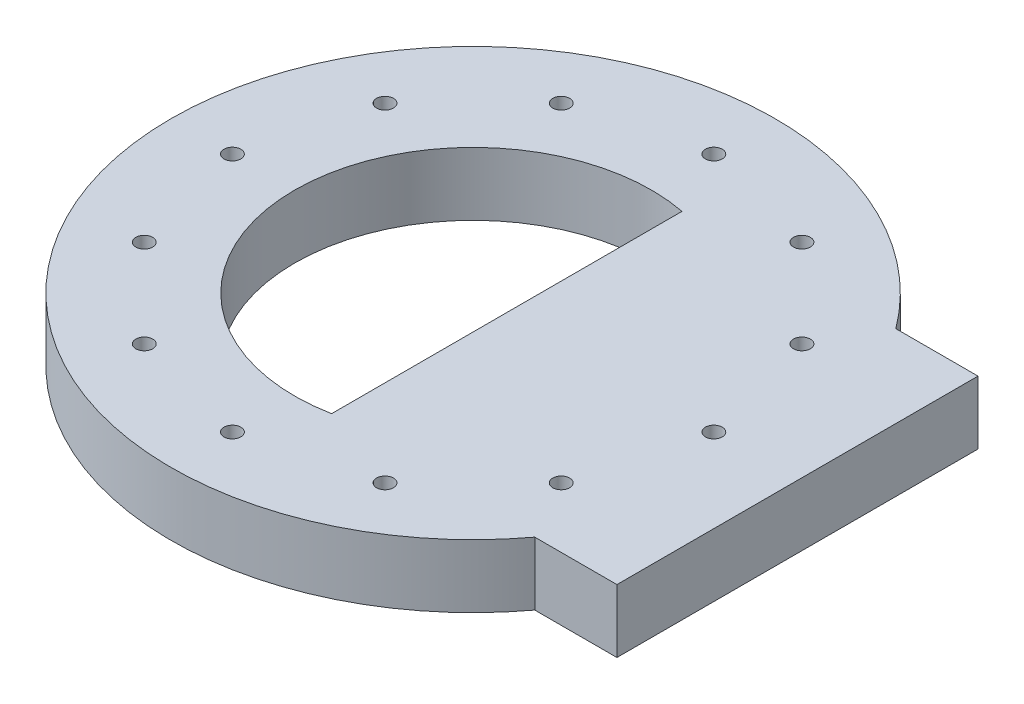
from build123d import *

# Parameters (mm, degrees)
SKETCH1_R           = 127.508
SKETCH1_R_2         = 75.311
SKETCH1_R_3         = 3.5687
BOSS_EXTRUDE1_DEPTH = 26.67
BOSS_EXTRUDE2_DEPTH = 26.67


with BuildPart() as part:
    # Sketch1 → Boss-Extrude1 (new body)
    with BuildSketch(Plane(origin=(0, 0, 0), x_dir=(1, 0, 0), z_dir=(0, 1, 0))):
        Circle(SKETCH1_R)
        Circle(SKETCH1_R_2, mode=Mode.SUBTRACT)
        with Locations((0, 101.6)):
            Circle(SKETCH1_R_3, mode=Mode.SUBTRACT)
        with Locations((50.8, 87.988181024)):
            Circle(SKETCH1_R_3, mode=Mode.SUBTRACT)
        with Locations((87.988181025, 50.8)):
            Circle(SKETCH1_R_3, mode=Mode.SUBTRACT)
        with Locations((101.6, 0)):
            Circle(SKETCH1_R_3, mode=Mode.SUBTRACT)
        with Locations((87.988181025, -50.8)):
            Circle(SKETCH1_R_3, mode=Mode.SUBTRACT)
        with Locations((50.8, -87.988181024)):
            Circle(SKETCH1_R_3, mode=Mode.SUBTRACT)
        with Locations((0, -101.6)):
            Circle(SKETCH1_R_3, mode=Mode.SUBTRACT)
        with Locations((-50.8, -87.988181025)):
            Circle(SKETCH1_R_3, mode=Mode.SUBTRACT)
        with Locations((-87.988181024, -50.8)):
            Circle(SKETCH1_R_3, mode=Mode.SUBTRACT)
        with Locations((-101.6, 0)):
            Circle(SKETCH1_R_3, mode=Mode.SUBTRACT)
        with Locations((-87.988181024, 50.8)):
            Circle(SKETCH1_R_3, mode=Mode.SUBTRACT)
        with Locations((-50.8, 87.988181024)):
            Circle(SKETCH1_R_3, mode=Mode.SUBTRACT)
    extrude(amount=BOSS_EXTRUDE1_DEPTH)

    # Sketch2 → Boss-Extrude2 (add, through all)
    with BuildSketch(Plane(origin=(0, 26.67, 0), x_dir=(1, 0, 0), z_dir=(0, 1, 0))):
        with BuildLine():
            Line((14.224, 73.955557905), (14.224, -73.955557905))
            ThreePointArc((14.224, -73.955557905), (75.311, 0), (14.224, 73.955557905))
        make_face()
        with BuildLine():
            Line((136.906, 76.2), (136.906, -76.2))
            Line((136.906, -76.2), (102.23429006, -76.2))
            ThreePointArc((102.23429006, -76.2), (127.508, 0), (102.23429006, 76.2))
            Line((102.23429006, 76.2), (136.906, 76.2))
        make_face()
    extrude(amount=-BOSS_EXTRUDE2_DEPTH)


solid = part.part
